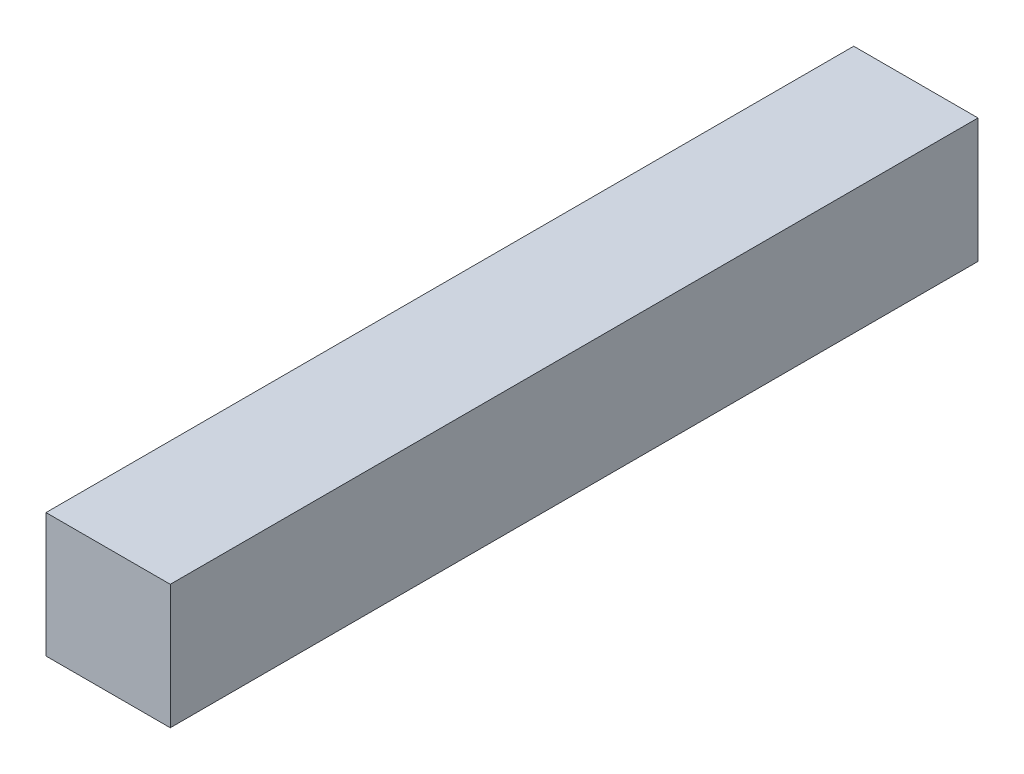
from build123d import *

# Parameters (mm, degrees)
SKETCH1_W           = 14
SKETCH1_H           = 14
BOSS_EXTRUDE1_DEPTH = 91


with BuildPart() as part:
    # Sketch1 → Boss-Extrude1 (new body)
    with BuildSketch(Plane.XY):
        Rectangle(SKETCH1_W, SKETCH1_H)
    extrude(amount=BOSS_EXTRUDE1_DEPTH)


solid = part.part
